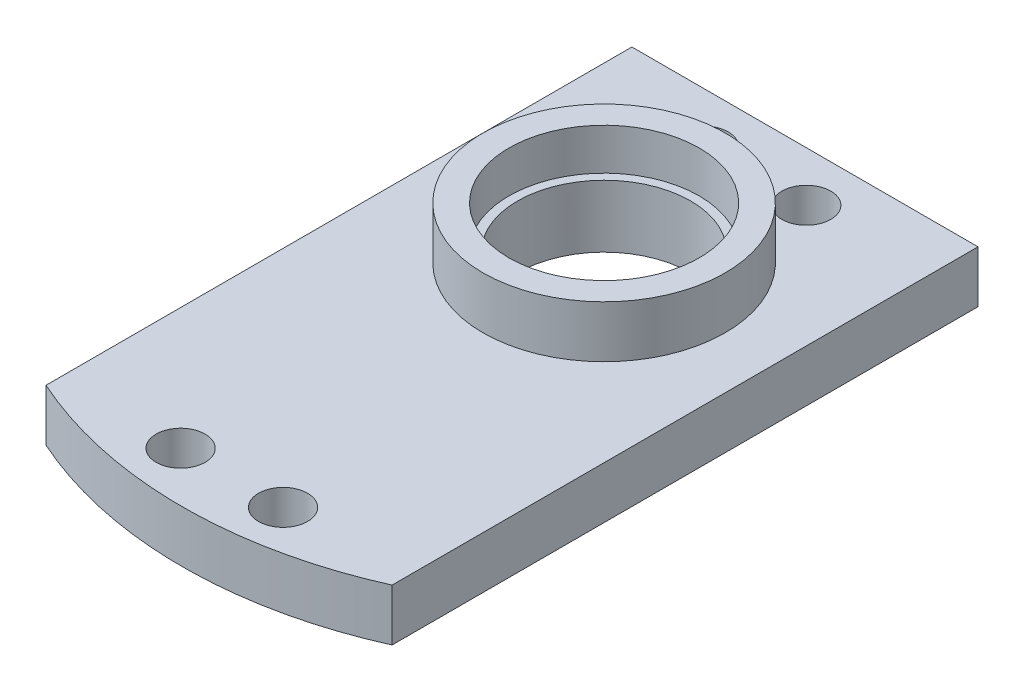
from build123d import *

# Parameters (mm, degrees)
SKETCH1_W             = 31.75
SKETCH1_H             = 57.15
BOSS_EXTRUDE1_DEPTH   = 4.7625
SKETCH2_R             = 11.1125
BOSS_EXTRUDE2_DEPTH   = 4.7625
SKETCH3_R             = 8.73125
CUT_EXTRUDE1_DEPTH    = 3.81
SKETCH4_R             = 7.9375
CUT_EXTRUDE2_DEPTH    = 7.9375
F_8_CLEARANCE_HOLE2_D = 4.4958
CUT_EXTRUDE3_DEPTH    = 5.7625


with BuildPart() as part:
    # Sketch1 → Boss-Extrude1 (new body)
    with BuildSketch(Plane(origin=(0, 0, 0), x_dir=(1, 0, 0), z_dir=(0, 1, 0))):
        Rectangle(SKETCH1_W, SKETCH1_H)
    extrude(amount=BOSS_EXTRUDE1_DEPTH)

    # Sketch2 → Boss-Extrude2 (add)
    with BuildSketch(Plane(origin=(0, 4.7625, 0), x_dir=(1, 0, 0), z_dir=(0, 1, 0))):
        with Locations((0, 10.15000002)):
            Circle(SKETCH2_R)
    extrude(amount=BOSS_EXTRUDE2_DEPTH)

    # Sketch3 → Cut-Extrude1 (cut)
    with BuildSketch(Plane(origin=(0, 9.525, 0), x_dir=(1, 0, 0), z_dir=(0, 1, 0))):
        with Locations((0, 10.15000002)):
            Circle(SKETCH3_R)
    extrude(amount=-CUT_EXTRUDE1_DEPTH, mode=Mode.SUBTRACT)

    # Sketch4 → Cut-Extrude2 (cut)
    with BuildSketch(Plane.XZ):
        with Locations((0, -10.15000002)):
            Circle(SKETCH4_R)
    extrude(amount=-CUT_EXTRUDE2_DEPTH, mode=Mode.SUBTRACT)

    # #8 Clearance Hole2 (through all)
    with Locations(Plane(origin=(0, 0, 0), x_dir=(-1, 0, 0), z_dir=(0, -1, 0))):
        with Locations((-4.7, 24.00000002), (4.7, -23.99999998), (4.7, 24.00000002), (-4.7, -23.99999998)):
            Hole(F_8_CLEARANCE_HOLE2_D / 2)

    # Sketch8 → Cut-Extrude3 (cut, through all)
    with BuildSketch(Plane(origin=(0, 4.7625, 0), x_dir=(1, 0, 0), z_dir=(0, 1, 0))):
        with BuildLine():
            ThreePointArc((15.875, -25.171523185), (8.117870402, -27.7145719), (0, -28.575))
            Line((0, -28.575), (15.875, -28.575))
            Line((15.875, -28.575), (15.875, -25.171523185))
        make_face()
        with BuildLine():
            ThreePointArc((0, -28.575), (-8.117870402, -27.7145719), (-15.875, -25.171523185))
            Line((-15.875, -25.171523185), (-15.875, -28.575))
            Line((-15.875, -28.575), (0, -28.575))
        make_face()
    extrude(amount=-CUT_EXTRUDE3_DEPTH, mode=Mode.SUBTRACT)


solid = part.part
